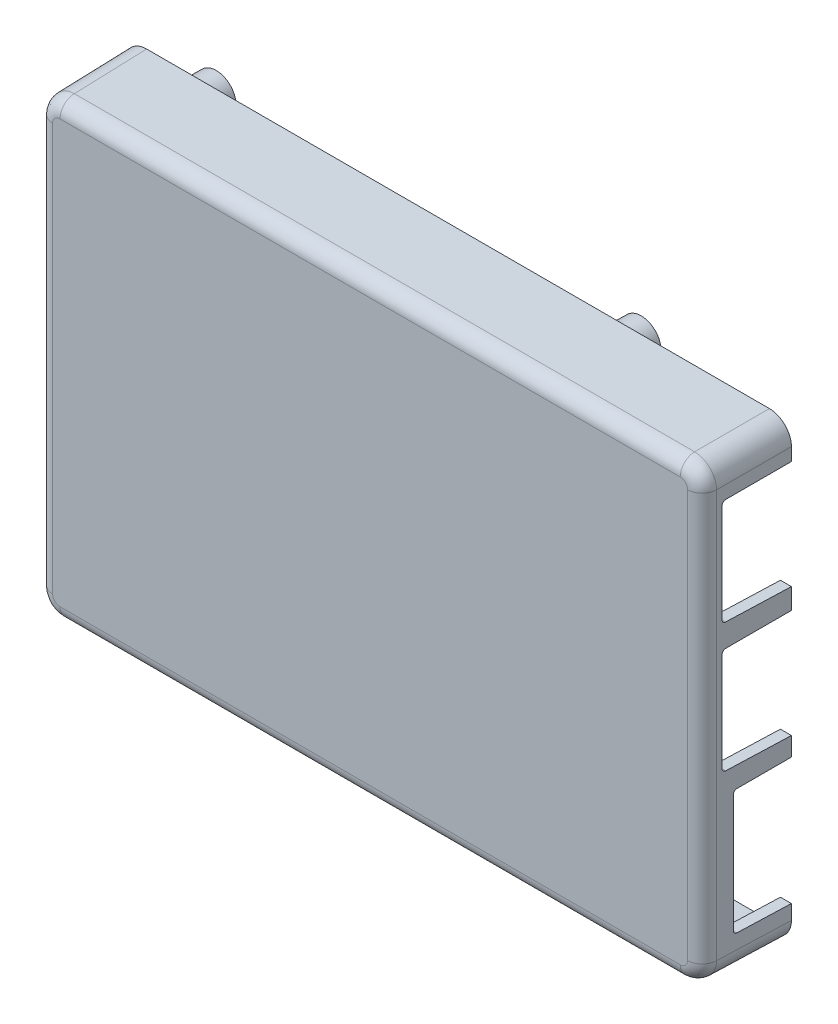
from build123d import *

# Parameters (mm, degrees)
SKETCH1_W                    = 91
SKETCH1_H                    = 62
SKETCH1_W_2                  = 88
SKETCH1_H_2                  = 59
WALLS_DEPTH                  = 12
SKETCH2_W                    = 91
SKETCH2_H                    = 62
BASE_DEPTH                   = 1.5
SKETCH3_R                    = 3
STANDOFFS_DEPTH              = 16.5
STANDOFFS_DRAFT              = 1
STANDOFFS_PROFILE_2_DEPTH    = 16.5
STANDOFFS_PROFILE_2_DRAFT    = 1
STANDOFFS_PROFILE_3_DEPTH    = 16.5
STANDOFFS_PROFILE_3_DRAFT    = 1
STANDOFFS_PROFILE_4_DEPTH    = 16.5
STANDOFFS_PROFILE_4_DRAFT    = 1
M2X0_4_TAPPED_HOLE1_D        = 1.6
M2X0_4_TAPPED_HOLE1_DEPTH    = 5
M2X0_4_TAPPED_HOLE1_TIP      = 0.480688495
USB_START                    = 30
SKETCH6_W                    = 14.2
SKETCH6_H                    = 17.304
SKETCH6_W_2                  = 16.490000002
SKETCH6_H_2                  = 14.78
USB_AND_ETHERNET_PORTS_DEPTH = 27.349356695
DRAFT1_ANGLE                 = -1
DRAFT2_ANGLE                 = 1
FILLET1_R                    = 3
FILLET2_R                    = 1.5
FILLET3_R                    = 2
FILLET4_R                    = 0.5
DRAFT3_ANGLE                 = 1
FILLET5_R                    = 0.5


with BuildPart() as part:
    # Sketch1 → Walls (new body)
    with BuildSketch(Plane.XY):
        Rectangle(SKETCH1_W, SKETCH1_H)
        Rectangle(SKETCH1_W_2, SKETCH1_H_2, mode=Mode.SUBTRACT)
    extrude(amount=WALLS_DEPTH)

    # Sketch2 → Base (add)
    with BuildSketch(Plane.XY.offset(12)):
        Rectangle(SKETCH2_W, SKETCH2_H)
    extrude(amount=-BASE_DEPTH)


with BuildPart() as standoffs_tool:
    # Sketch3 → Standoffs (with draft: the straight prism first)
    with BuildSketch(Plane(origin=(0, 0, 10.5), x_dir=(-1, 0, 0), z_dir=(0, 0, -1))):
        with Locations((39, -24.5)):
            Circle(SKETCH3_R)
    extrude(amount=STANDOFFS_DEPTH)
    # Standoffs: the draft: its side faces are tilted about the plane it starts from
    standoffs_sides = [standoffs_tool.faces().sort_by_distance(p)[0] for p in [
        (-36, -24.5, 2.25),
    ]]
    draft(standoffs_sides, Plane(origin=(0, 0, 10.5), x_dir=(-1, 0, 0), z_dir=(0, 0, -1)), STANDOFFS_DRAFT)


with BuildPart() as part_1:
    add(part.part)

    # Standoffs: add standoffs_tool
    add(standoffs_tool.part)


with BuildPart() as standoffs_profile_2_tool:
    # Sketch3 → Standoffs profile 2 (with draft: the straight prism first)
    with BuildSketch(Plane(origin=(0, 0, 10.5), x_dir=(-1, 0, 0), z_dir=(0, 0, -1))):
        with Locations((-19, -24.5)):
            Circle(SKETCH3_R)
    extrude(amount=STANDOFFS_PROFILE_2_DEPTH)
    # Standoffs profile 2: the draft: its side faces are tilted about the plane it starts from
    standoffs_profile_2_sides = [standoffs_profile_2_tool.faces().sort_by_distance(p)[0] for p in [
        (22, -24.5, 2.25),
    ]]
    draft(standoffs_profile_2_sides, Plane(origin=(0, 0, 10.5), x_dir=(-1, 0, 0), z_dir=(0, 0, -1)), STANDOFFS_PROFILE_2_DRAFT)


with BuildPart() as part_2:
    add(part_1.part)

    # Standoffs profile 2: add standoffs_profile_2_tool
    add(standoffs_profile_2_tool.part)


with BuildPart() as standoffs_profile_3_tool:
    # Sketch3 → Standoffs profile 3 (with draft: the straight prism first)
    with BuildSketch(Plane(origin=(0, 0, 10.5), x_dir=(-1, 0, 0), z_dir=(0, 0, -1))):
        with Locations((-19, 24.5)):
            Circle(SKETCH3_R)
    extrude(amount=STANDOFFS_PROFILE_3_DEPTH)
    # Standoffs profile 3: the draft: its side faces are tilted about the plane it starts from
    standoffs_profile_3_sides = [standoffs_profile_3_tool.faces().sort_by_distance(p)[0] for p in [
        (22, 24.5, 2.25),
    ]]
    draft(standoffs_profile_3_sides, Plane(origin=(0, 0, 10.5), x_dir=(-1, 0, 0), z_dir=(0, 0, -1)), STANDOFFS_PROFILE_3_DRAFT)


with BuildPart() as part_3:
    add(part_2.part)

    # Standoffs profile 3: add standoffs_profile_3_tool
    add(standoffs_profile_3_tool.part)


with BuildPart() as standoffs_profile_4_tool:
    # Sketch3 → Standoffs profile 4 (with draft: the straight prism first)
    with BuildSketch(Plane(origin=(0, 0, 10.5), x_dir=(-1, 0, 0), z_dir=(0, 0, -1))):
        with Locations((39, 24.5)):
            Circle(SKETCH3_R)
    extrude(amount=STANDOFFS_PROFILE_4_DEPTH)
    # Standoffs profile 4: the draft: its side faces are tilted about the plane it starts from
    standoffs_profile_4_sides = [standoffs_profile_4_tool.faces().sort_by_distance(p)[0] for p in [
        (-36, 24.5, 2.25),
    ]]
    draft(standoffs_profile_4_sides, Plane(origin=(0, 0, 10.5), x_dir=(-1, 0, 0), z_dir=(0, 0, -1)), STANDOFFS_PROFILE_4_DRAFT)


with BuildPart() as part_4:
    add(part_3.part)

    # Standoffs profile 4: add standoffs_profile_4_tool
    add(standoffs_profile_4_tool.part)

    # M2x0.4 Tapped Hole1
    with Locations(Plane(origin=(0, 0, -6), x_dir=(-1, 0, 0), z_dir=(0, 0, -1))):
        with Locations((39, -24.5), (-19, -24.5), (-19, 24.5), (39, 24.5)):
            Hole(M2X0_4_TAPPED_HOLE1_D / 2, depth=M2X0_4_TAPPED_HOLE1_DEPTH)
            with Locations((0, 0, -(M2X0_4_TAPPED_HOLE1_DEPTH + M2X0_4_TAPPED_HOLE1_TIP / 2))):  # 118° drill point
                Cone(0, M2X0_4_TAPPED_HOLE1_D / 2, M2X0_4_TAPPED_HOLE1_TIP, mode=Mode.SUBTRACT)

    # Sketch6 → USB and Ethernet Ports (cut, through all)
    with BuildSketch(Plane(origin=(0, 0, 0), x_dir=(0, 0, -1), z_dir=(1, 0, 0)).offset(USB_START)):
        with Locations((-0.7, -17.348)):
            Rectangle(SKETCH6_W, SKETCH6_H)
        with Locations((-1.054999999, 1.25)):
            Rectangle(SKETCH6_W_2, SKETCH6_H_2)
        with Locations((-1.054999999, 18.85)):
            Rectangle(SKETCH6_W_2, SKETCH6_H_2)
    extrude(amount=USB_AND_ETHERNET_PORTS_DEPTH, mode=Mode.SUBTRACT)

    # Draft1
    draft1_faces = [part_4.faces().sort_by_distance(p)[0] for p in [
        (45.5, -28.5, 0.631506136),
        (0, -31, 6),
        (-45.5, 0, 6),
        (0, 31, 6),
    ]]
    draft(draft1_faces, Plane(origin=(0, 0, 0), x_dir=(-1, 0, 0), z_dir=(0, 0, -1)), DRAFT1_ANGLE)

    # Draft2
    draft2_faces = [part_4.faces().sort_by_distance(p)[0] for p in [
        (44, -27.75, 0.59927039),
        (0, -29.5, 5.25),
        (-44, 0, 5.25),
        (0, 29.5, 5.25),
    ]]
    draft(draft2_faces, Plane(origin=(0, 0, 0), x_dir=(-1, 0, 0), z_dir=(0, 0, -1)), DRAFT2_ANGLE)

    # Fillet1
    fillet1_edges = [part_4.edges().sort_by_distance(p)[0] for p in [
        (45.39526961, 30.89526961, 6),
        (45.39526961, -30.89526961, 6),
        (-45.39526961, -30.89526961, 6),
        (-45.39526961, 30.89526961, 6),
    ]]
    fillet(fillet1_edges, radius=FILLET1_R)

    # Fillet2
    fillet2_edges = [part_4.edges().sort_by_distance(p)[0] for p in [
        (43.908360909, -29.408360909, 5.25),
        (43.908360909, 29.408360909, 5.25),
        (-43.908360909, -29.408360909, 5.25),
        (-43.908360909, 29.408360909, 5.25),
    ]]
    fillet(fillet2_edges, radius=FILLET2_R)

    # Fillet3
    fillet3_edges = [part_4.edges().sort_by_distance(p)[0] for p in [
        (-45.290539221, 0, 12),
        (0, 30.790539221, 12),
        (0, -30.790539221, 12),
        (45.290539221, 0, 12),
        (-44.412048804, -29.912048804, 12),
        (44.412048804, 29.912048804, 12),
        (44.412048804, -29.912048804, 12),
        (-44.412048804, 29.912048804, 12),
    ]]
    fillet(fillet3_edges, radius=FILLET3_R)

    # Fillet4
    fillet4_edges = [part_4.edges().sort_by_distance(p)[0] for p in [
        (0, 29.316721818, 10.5),
        (-43.816721818, 0, 10.5),
        (43.816721818, 0, 10.5),
        (0, -29.316721818, 10.5),
        (-43.37747661, -28.87747661, 10.5),
        (43.37747661, 28.87747661, 10.5),
        (43.37747661, -28.87747661, 10.5),
        (-43.37747661, 28.87747661, 10.5),
        (-36, -24.5, 10.5),
        (22, -24.5, 10.5),
        (22, 24.5, 10.5),
        (-36, 24.5, 10.5),
    ]]
    fillet(fillet4_edges, radius=FILLET4_R)

    # Draft3
    draft3_faces = [part_4.faces().sort_by_distance(p)[0] for p in [
        (44.681925247, -26, 3.9),
        (44.668833948, 11.46, 4.65),
        (44.668833948, -6.14, 4.65),
        (44.681925247, -8.696, 3.9),
        (44.668833948, 8.64, 4.65),
        (44.668833948, 26.24, 4.65),
    ]]
    draft(draft3_faces, Plane(origin=(0, 0, 0), x_dir=(-1, 0, 0), z_dir=(0, 0, -1)), DRAFT3_ANGLE)

    # Fillet5
    fillet5_edges = [part_4.edges().sort_by_distance(p)[0] for p in [
        (44.587667896, 8.477667896, 9.3),
        (44.587667896, -5.977667896, 9.3),
        (44.587667896, 26.077667896, 9.3),
        (44.587667896, 11.622332104, 9.3),
        (44.613850494, -8.832149506, 7.8),
        (44.613850494, -25.863850494, 7.8),
    ]]
    fillet(fillet5_edges, radius=FILLET5_R)


solid = part_4.part
